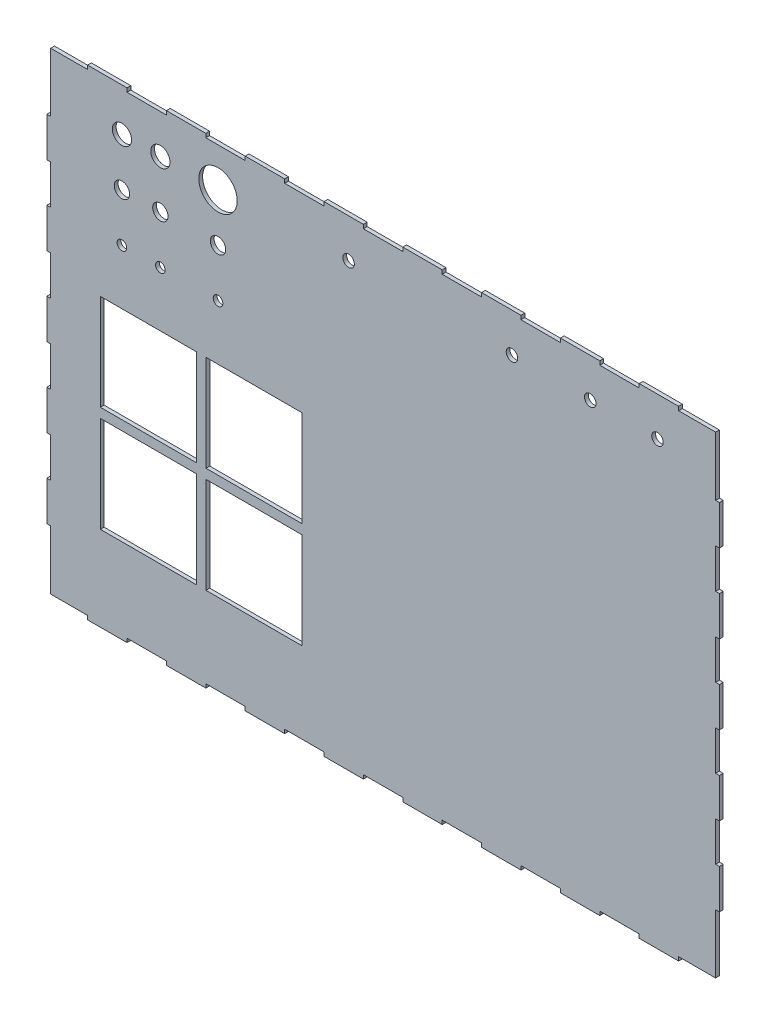
from build123d import *

# Parameters (mm, degrees)
SKETCH1_R           = 63.5
SKETCH1_R_2         = 76.2
SKETCH1_R_3         = 127
SKETCH1_R_4         = 101.6
SKETCH1_R_5         = 254
SKETCH1_W           = 1270
SKETCH1_H           = 1270
BOSS_EXTRUDE1_DEPTH = 50
SCALE1_SCALE        = 0.04


with BuildPart() as part:
    # Sketch1 → Boss-Extrude1 (new body)
    with BuildSketch(Plane.XY):
        Polygon((50.8, 3435.35), (50.8, 3956.05), (0, 3956.05), (0, 4476.75), (50.8, 4476.75), (50.8, 4997.45), (0, 4997.45), (0, 5518.15), (50.8, 5518.15), (50.8, 6299.2), (539.75, 6299.2), (539.75, 6350), (1060.45, 6350), (1060.45, 6299.2), (1581.15, 6299.2), (1581.15, 6350), (2101.85, 6350), (2101.85, 6299.2), (2622.55, 6299.2), (2622.55, 6350), (3143.25, 6350), (3143.25, 6299.2), (3663.95, 6299.2), (3663.95, 6350), (4184.65, 6350), (4184.65, 6299.2), (4705.35, 6299.2), (4705.35, 6350), (5226.05, 6350), (5226.05, 6299.2), (5746.75, 6299.2), (5746.75, 6350), (6267.45, 6350), (6267.45, 6299.2), (6788.15, 6299.2), (6788.15, 6350), (7308.85, 6350), (7308.85, 6299.2), (7829.55, 6299.2), (7829.55, 6350), (8350.25, 6350), (8350.25, 6299.2), (8839.2, 6299.2), (8839.2, 6038.85), (8839.2, 5518.15), (8890, 5518.15), (8890, 4997.45), (8839.2, 4997.45), (8839.2, 4476.75), (8890, 4476.75), (8890, 3956.05), (8839.2, 3956.05), (8839.2, 3435.35), (8890, 3435.35), (8890, 2914.65), (8839.2, 2914.65), (8839.2, 2393.95), (8890, 2393.95), (8890, 1873.25), (8839.2, 1873.25), (8839.2, 1352.55), (8890, 1352.55), (8890, 831.85), (8839.2, 831.85), (8839.2, 50.8), (8350.25, 50.8), (8350.25, 0), (7829.55, 0), (7829.55, 50.8), (7308.85, 50.8), (7308.85, 0), (6788.15, 0), (6788.15, 50.8), (6267.45, 50.8), (6267.45, 0), (5746.75, 0), (5746.75, 50.8), (5226.05, 50.8), (5226.05, 0), (4705.35, 0), (4705.35, 50.8), (4184.65, 50.8), (4184.65, 0), (3663.95, 0), (3663.95, 50.8), (3143.25, 50.8), (3143.25, 0), (2622.55, 0), (2622.55, 50.8), (2101.85, 50.8), (2101.85, 0), (1581.15, 0), (1581.15, 50.8), (1060.45, 50.8), (1060.45, 0), (539.75, 0), (539.75, 50.8), (50.8, 50.8), (50.8, 311.15), (50.8, 831.85), (0, 831.85), (0, 1352.55), (50.8, 1352.55), (50.8, 1873.25), (0, 1873.25), (0, 2393.95), (50.8, 2393.95), (50.8, 2914.65), (0, 2914.65), (0, 3435.35), align=None)
        with Locations((2263.093189832, 4514.095537704)):
            Circle(SKETCH1_R, mode=Mode.SUBTRACT)
        with Locations((7182.429020432, 5834.895537704)):
            Circle(SKETCH1_R_2, mode=Mode.SUBTRACT)
        with Locations((6147.900253832, 5834.895537704)):
            Circle(SKETCH1_R_2, mode=Mode.SUBTRACT)
        with Locations((8071.429020432, 5834.895537704)):
            Circle(SKETCH1_R_2, mode=Mode.SUBTRACT)
        with Locations((3988.900253832, 5834.895537704)):
            Circle(SKETCH1_R_2, mode=Mode.SUBTRACT)
        with Locations((993.093189832, 5784.095537704)):
            Circle(SKETCH1_R_3, mode=Mode.SUBTRACT)
        with Locations((993.093189832, 5149.095537704)):
            Circle(SKETCH1_R_4, mode=Mode.SUBTRACT)
        with Locations((993.093189832, 4514.095537704)):
            Circle(SKETCH1_R, mode=Mode.SUBTRACT)
        with Locations((1501.093189832, 5784.095537704)):
            Circle(SKETCH1_R_3, mode=Mode.SUBTRACT)
        with Locations((1501.093189832, 5149.095537704)):
            Circle(SKETCH1_R_4, mode=Mode.SUBTRACT)
        with Locations((1501.093189832, 4514.095537704)):
            Circle(SKETCH1_R, mode=Mode.SUBTRACT)
        with Locations((2263.093189832, 5784.095537704)):
            Circle(SKETCH1_R_5, mode=Mode.SUBTRACT)
        with Locations((2263.093189832, 5149.095537704)):
            Circle(SKETCH1_R_4, mode=Mode.SUBTRACT)
        with Locations((2739.3392, 3152.6226)):
            Rectangle(SKETCH1_W, SKETCH1_H, mode=Mode.SUBTRACT)
        with Locations((2739.3392, 1755.6226)):
            Rectangle(SKETCH1_W, SKETCH1_H, mode=Mode.SUBTRACT)
        with Locations((1342.3392, 1755.6226)):
            Rectangle(SKETCH1_W, SKETCH1_H, mode=Mode.SUBTRACT)
        with Locations((1342.3392, 3152.6226)):
            Rectangle(SKETCH1_W, SKETCH1_H, mode=Mode.SUBTRACT)
    extrude(amount=BOSS_EXTRUDE1_DEPTH)


with BuildPart() as part_1:
    # Scale1: scaled about (4784.759817545, 3245.327855947, 25)
    add(part.part.scale(SCALE1_SCALE).moved(Location((4593.369424843, 3115.514741709, 24))))


solid = part_1.part
